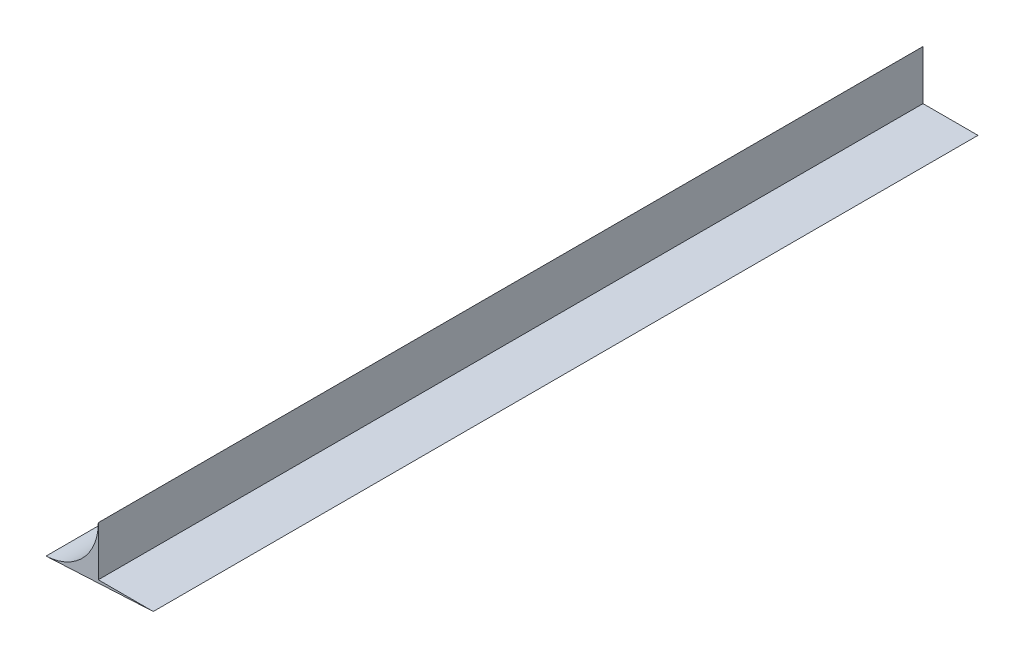
from build123d import *

# Parameters (mm, degrees)
BOSS_EXTRUDE1_DEPTH = 225


with BuildPart() as part:
    # Sketch1 → Boss-Extrude1 (new body)
    with BuildSketch(Plane.XY):
        with BuildLine():
            Line((0, 0), (0, 13.5))
            ThreePointArc((0, 13.5), (-4.134331164, 3.137217092), (-14.266538063, -1.533794267))
            Line((-14.266538063, -1.533794267), (15, 0))
            Line((15, 0), (0, 0))
        make_face()
    extrude(amount=BOSS_EXTRUDE1_DEPTH)


solid = part.part
